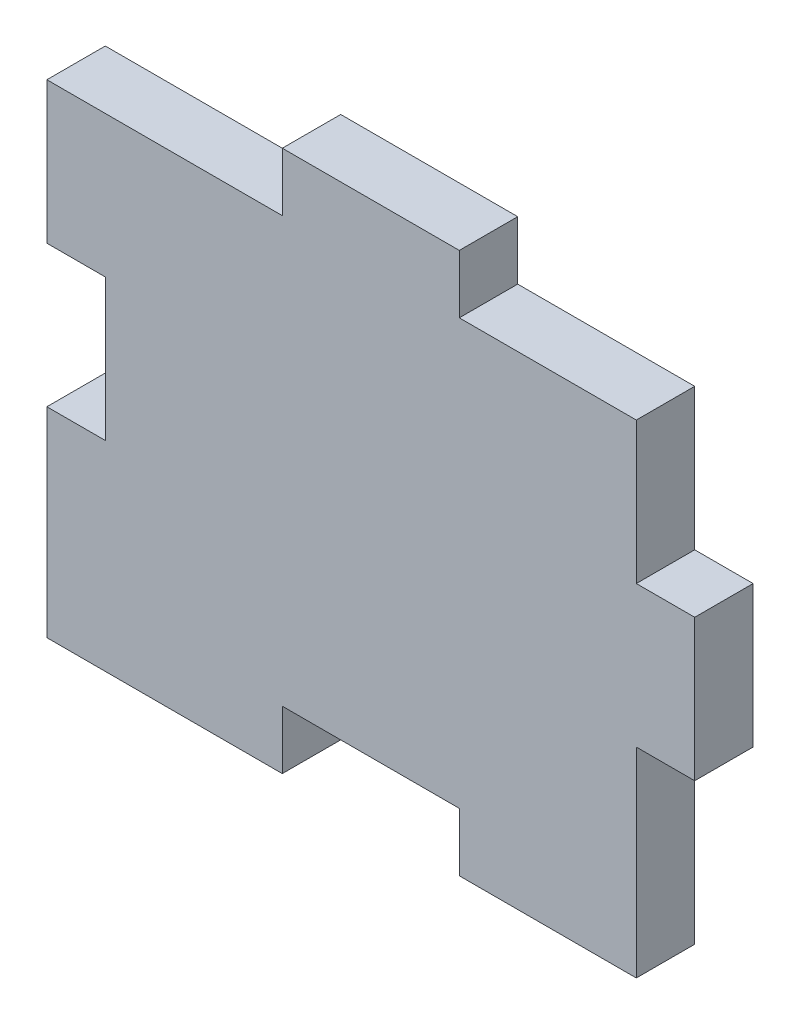
from build123d import *

# Parameters (mm, degrees)
BOSS_EXTRUDE1_DEPTH = 5.5


with BuildPart() as part:
    # Sketch1 → Boss-Extrude1 (new body)
    with BuildSketch(Plane.XY):
        Polygon((16.666666667, 0), (33.333333333, 0), (33.333333333, -5.5), (50, -5.5), (50, 0), (50, 13.333333333), (55.5, 13.333333333), (55.5, 26.666666667), (50, 26.666666667), (50, 40), (33.333333333, 40), (33.333333333, 45.5), (16.666666667, 45.5), (16.666666667, 40), (0, 40), (-5.5, 40), (-5.5, 26.666666667), (0, 26.666666667), (0, 13.333333333), (-5.5, 13.333333333), (-5.5, -5.5), (0, -5.5), (16.666666667, -5.5), align=None)
    extrude(amount=BOSS_EXTRUDE1_DEPTH)


solid = part.part
